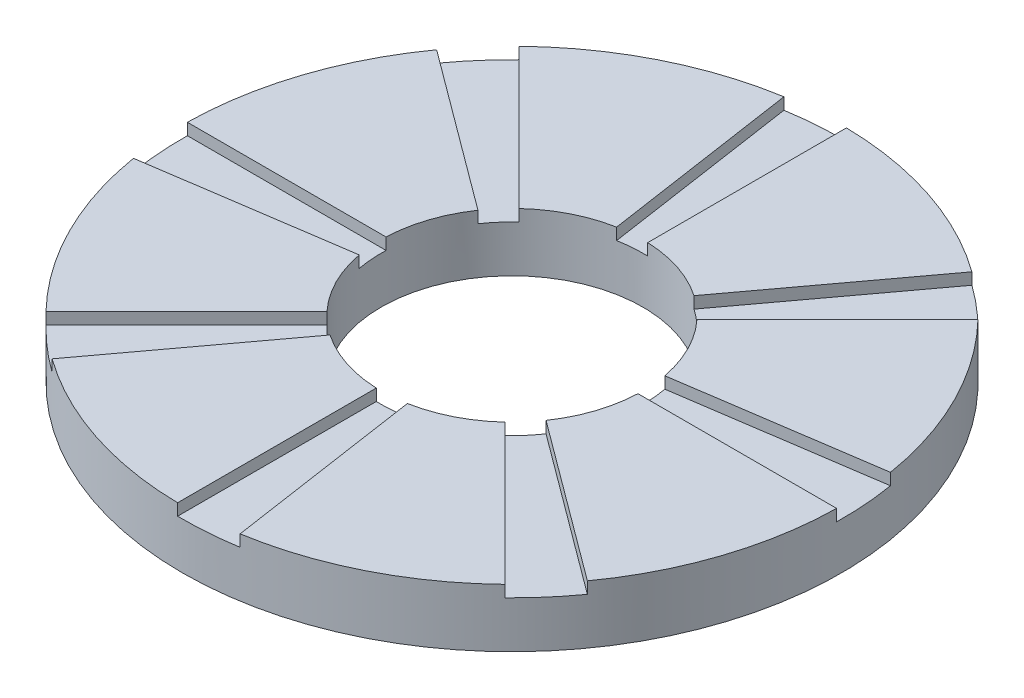
from build123d import *

# Parameters (mm, degrees)
SKETCH1_R           = 56.486183981
SKETCH1_R_2         = 22.440533472
BOSS_EXTRUDE1_DEPTH = 10
CUT_EXTRUDE1_DEPTH  = 2
CIRPATTERN1_COUNT   = 8


with BuildPart() as part:
    # Sketch1 → Boss-Extrude1 (new body)
    with BuildSketch(Plane(origin=(0, 0, 0), x_dir=(1, 0, 0), z_dir=(0, 1, 0))):
        Circle(SKETCH1_R)
        Circle(SKETCH1_R_2, mode=Mode.SUBTRACT)
    extrude(amount=BOSS_EXTRUDE1_DEPTH)

    # Sketch2 → Cut-Extrude1 (cut)
    with BuildSketch(Plane(origin=(0, 10, 0), x_dir=(1, 0, 0), z_dir=(0, 1, 0))):
        with BuildLine():
            Line((-9.135137375, 55.742607096), (-1.420081042, 3.855253414))
            ThreePointArc((-1.420081042, 3.855253414), (-0.302945279, 4.097295841), (0.837640155, 4.022184484))
            Line((0.837640155, 4.022184484), (0.837640155, 56.479972908))
            ThreePointArc((0.837640155, 56.479972908), (-4.165098092, 56.332414635), (-9.135137375, 55.742607096))
        make_face()
    cut_extrude1 = extrude(amount=-CUT_EXTRUDE1_DEPTH, mode=Mode.SUBTRACT)

    # CirPattern1: Cut-Extrude1 ×8 about axis
    cirpattern1_axis = Axis((0, 0, 0), (0, 1, 0))
    for i in range(1, CIRPATTERN1_COUNT):
        add(cut_extrude1.rotate(cirpattern1_axis, i * 360 / CIRPATTERN1_COUNT), mode=Mode.SUBTRACT)


solid = part.part
